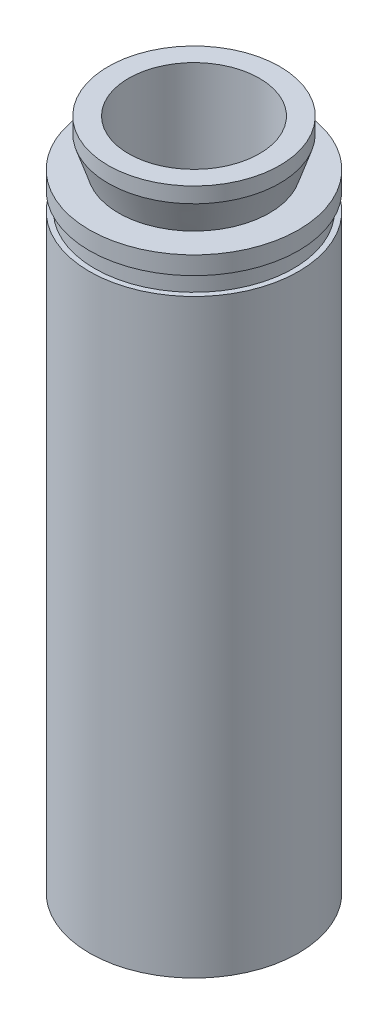
from build123d import *


with BuildPart() as part:
    # Sketch1 → Revolve1 (revolve)
    with BuildSketch(Plane.XY):
        Polygon((-17.45, 0), (-20.3, 0), (-20.3, 114.6), (-19.3, 114.6), (-19.3, 118.1), (-20.3, 118.1), (-20.3, 121.6), (-14.65, 121.6), (-16.65, 127.6), (-16.65, 130.6), (-12.7, 130.6), (-12.7, 111.6), (-17.45, 111.6), align=None)
    revolve(axis=Axis((0, 0, 0), (0, 1, 0)))


solid = part.part
